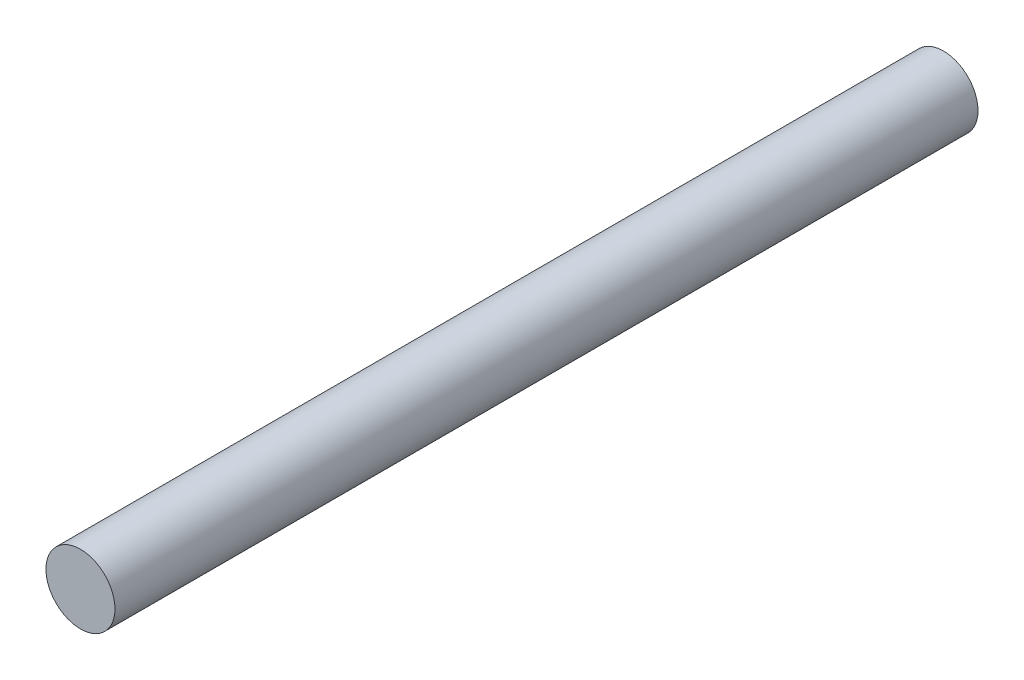
from build123d import *

# Parameters (mm, degrees)
SKETCH1_R           = 4
BOSS_EXTRUDE1_DEPTH = 100


with BuildPart() as part:
    # Sketch1 → Boss-Extrude1 (new body)
    with BuildSketch(Plane.XY):
        with Locations((-1.755568551, 6.907780603)):
            Circle(SKETCH1_R)
    extrude(amount=BOSS_EXTRUDE1_DEPTH)


solid = part.part
